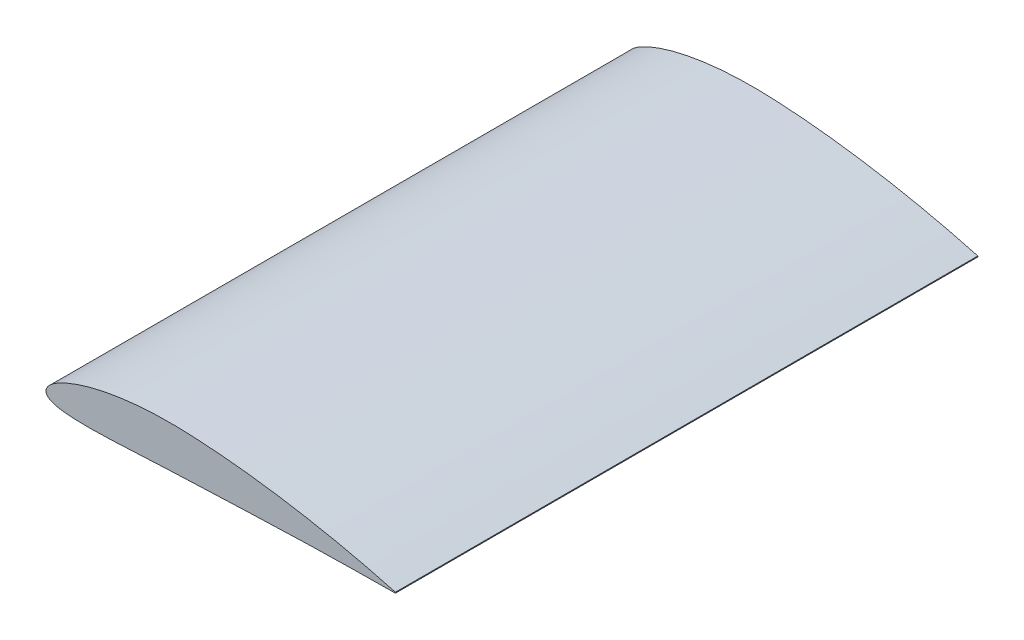
from build123d import *

# Parameters (mm, degrees)
EXTRUDE_1_DEPTH = 250


with BuildPart() as part:
    # Эскиз1 → Бобышка-Вытянуть1 (new body, symmetric)
    with BuildSketch(Plane.XY):
        with BuildLine():
            Line((0.05757, 0.74571), (0, 0))
            Line((0, 0), (0.00249, -0.14724))
            add(Edge.make_bspline(
                [(0.00249, -0.14724), (0.028864169, -0.445513844), (0.08330578, -1.0612113), (0.42267139, -1.966638227), (0.976281815, -2.838072896), (1.756459788, -3.647133325), (2.749077941, -4.393198402), (3.967143746, -5.082935859), (5.442296909, -5.728408867), (7.235698246, -6.338630634), (9.442776227, -6.918379999), (12.202598128, -7.466059916), (15.690525654, -7.967542476), (20.073738499, -8.391548086), (25.427942493, -8.696814173), (31.679981306, -8.851966619), (38.636878275, -8.851508296), (46.077368111, -8.713723896), (53.829146121, -8.46796963), (61.783851715, -8.143744238), (69.877177119, -7.766789504), (78.062513527, -7.359422717), (86.292927251, -6.940806212), (94.525650691, -6.527616544), (102.732598332, -6.133141503), (110.918529108, -5.765943991), (119.106037428, -5.438377986), (127.316854086, -5.133929605), (135.563054016, -4.803707911), (143.837285105, -4.467811421), (152.128632568, -4.128080756), (160.417875856, -3.790434721), (168.698244489, -3.458856865), (176.966416514, -3.13670755), (185.223122893, -2.826751698), (193.470052961, -2.531243905), (201.709043695, -2.251960889), (209.941894226, -1.990371725), (218.170315159, -1.747653748), (226.395881355, -1.524460053), (234.619974201, -1.321335461), (242.843439472, -1.138340626), (253.799028348, -0.921290824), (264.723718399, -0.743927691), (275.541156207, -0.603511416), (283.304824625, -0.51781703), (290.376932295, -0.451824554), (295.870764013, -0.407443063), (298.944589157, -0.385525491), (300, -0.378)],
                knots=[0, 0, 0, 0, 0.002951555, 0.006092605, 0.0094509, 0.013105035, 0.017145832, 0.021696099, 0.026921577, 0.033052787, 0.04041788, 0.049480062, 0.060872195, 0.075263112, 0.093030359, 0.113913711, 0.137122623, 0.161846788, 0.187529051, 0.213844768, 0.24060404, 0.267679501, 0.294919064, 0.322129352, 0.349224887, 0.376200636, 0.403190533, 0.430285051, 0.457482609, 0.484832061, 0.51220601, 0.539574277, 0.566902094, 0.594185889, 0.621429901, 0.648639753, 0.675821648, 0.702981565, 0.730124952, 0.757257324, 0.784383539, 0.811507209, 0.838628701, 0.892783781, 0.919594556, 0.94565005, 0.969591155, 0.989558995, 1, 1, 1, 1], degree=3))
            ThreePointArc((300, -0.378), (300.156572727, 0), (300, 0.378))
            add(Edge.make_bspline(
                [(300, 0.378), (298.986801288, 0.654023781), (296.064210837, 1.450219491), (290.8695985, 2.830006863), (284.219713445, 4.545150437), (276.935901935, 6.357610605), (269.347101537, 8.175439233), (261.636652195, 9.949932759), (253.874886054, 11.663682068), (246.086893811, 13.310849919), (238.281565095, 14.889420872), (230.462843896, 16.398357509), (222.633143967, 17.836911964), (214.794406789, 19.204085734), (206.94847769, 20.498865738), (199.097180514, 21.719793409), (191.242416875, 22.865402178), (183.386166154, 23.933862723), (175.530527282, 24.923138619), (167.67763175, 25.830811336), (159.830204076, 26.654405099), (151.990419631, 27.390865714), (144.164125102, 28.036767919), (136.354280569, 28.589612789), (128.583278445, 29.040291112), (120.889314832, 29.398079412), (113.294103258, 29.623979722), (105.787101592, 29.68811478), (98.338851666, 29.590618972), (90.93662471, 29.32921657), (83.58443153, 28.898261785), (76.290492602, 28.293607633), (69.066227461, 27.50993599), (61.926915226, 26.542878626), (54.893280374, 25.387877318), (47.995029113, 24.042445667), (41.277503811, 22.507579481), (34.812458524, 20.793138729), (28.71095809, 18.926237906), (23.124814608, 16.961123321), (18.21491807, 14.980002525), (14.088570948, 13.074733194), (10.751246243, 11.315492838), (8.113069416, 9.730323839), (6.040451698, 8.309565666), (4.40603392, 7.025075597), (3.110521348, 5.845566442), (2.085810802, 4.743114892), (1.283844996, 3.697135648), (0.685974492, 2.689946523), (0.258928679, 1.716942476), (0.122706698, 1.059890033), (0.05757, 0.74571)],
                knots=[0, 0, 0, 0, 0.0101622, 0.029313053, 0.052011605, 0.076619468, 0.101948061, 0.127526132, 0.153184131, 0.178867888, 0.204557903, 0.230245712, 0.255925967, 0.281594302, 0.30724642, 0.332878042, 0.358484538, 0.384061186, 0.409602822, 0.435103874, 0.460559416, 0.485959195, 0.51130307, 0.536551515, 0.561723366, 0.586628867, 0.611085431, 0.6352512, 0.659272176, 0.683163753, 0.706922144, 0.73053591, 0.7539832, 0.77723469, 0.800246382, 0.822950709, 0.845237155, 0.866915896, 0.887662335, 0.906968281, 0.924203157, 0.938878975, 0.950931611, 0.960693484, 0.968646729, 0.975232933, 0.980794744, 0.985583761, 0.989781539, 0.993521313, 0.996902113, 1, 1, 1, 1], degree=3))
        make_face()
    extrude(amount=EXTRUDE_1_DEPTH, both=True)


solid = part.part
